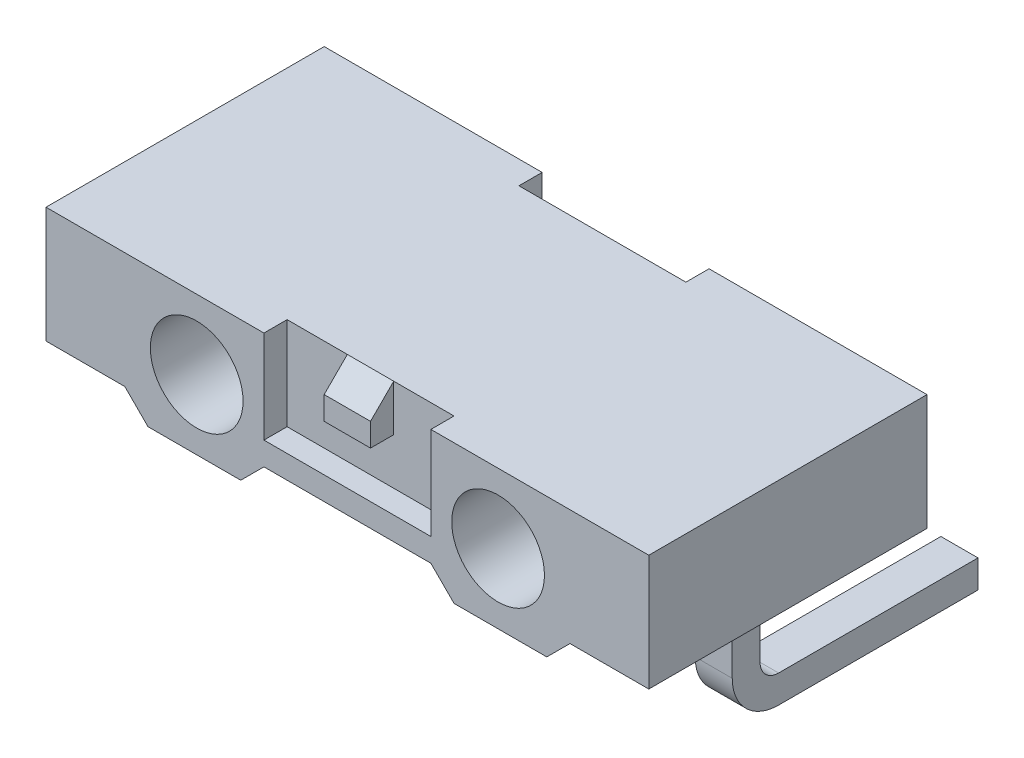
from build123d import *

# Parameters (mm, degrees)
SCHIZZO1_W                   = 13
SCHIZZO1_H                   = 2.5
ESTRUSIONE_ESTRUSIONE1_DEPTH = 3
ESTRUSIONE_ESTRUSIONE2_DEPTH = 6
SCHIZZO3_R                   = 1
TAGLIO_ESTRUSIONE1_DEPTH     = 7
TAGLIO_ESTRUSIONE2_DEPTH     = 0.5
SMUSSO1_SIZE                 = 0.5
ESTRUSIONE_ESTRUSIONE3_DEPTH = 0.4
RIPETIZIONE_A_L1_COUNT       = 2
RIPETIZIONE_A_L1_PITCH       = 5.2
RIPETIZIONE_A_L1_COL_COUNT   = 2
RIPETIZIONE_A_L1_COL_PITCH   = 5.2


with BuildPart() as part:
    # Schizzo1 → Estrusione-Estrusione1 (new body, symmetric)
    with BuildSketch(Plane.XY):
        Rectangle(SCHIZZO1_W, SCHIZZO1_H)
    extrude(amount=ESTRUSIONE_ESTRUSIONE1_DEPTH, both=True)

    # Schizzo2 → Estrusione-Estrusione2 (add)
    with BuildSketch(Plane.XY.offset(3)):
        Polygon((-4.8, -1.25), (-4.3, -1.75), (-2.3, -1.75), (-1.8, -1.25), (1.8, -1.25), (2.3, -1.75), (4.3, -1.75), (4.8, -1.25), (4.8, -0.938044121), (-4.8, -0.938044121), align=None)
    extrude(amount=-ESTRUSIONE_ESTRUSIONE2_DEPTH)

    # Schizzo3 → Taglio-Estrusione1 (cut, through all)
    with BuildSketch(Plane.XY.offset(3)):
        with Locations((-3.25, -0.25)):
            Circle(SCHIZZO3_R)
        with Locations((3.25, -0.25)):
            Circle(SCHIZZO3_R)
    extrude(amount=-TAGLIO_ESTRUSIONE1_DEPTH, mode=Mode.SUBTRACT)

    # Schizzo4 → Taglio-Estrusione2 (cut)
    with BuildSketch(Plane.XY.offset(3)):
        Polygon((-1.8, 1.25), (-0.501117074, 1.25), (-0.501117074, 0.25), (0.498882926, 0.25), (0.498882926, 1.25), (1.8, 1.25), (1.8, -0.75), (-1.8, -0.75), align=None)
    taglio_estrusione2 = extrude(amount=-TAGLIO_ESTRUSIONE2_DEPTH, mode=Mode.SUBTRACT)

    # Specchia2: Taglio-Estrusione2 across plane
    add(taglio_estrusione2.mirror(Plane.XY), mode=Mode.SUBTRACT)

    # Smusso1
    smusso1_edges = [part.edges().sort_by_distance(p)[0] for p in [
        (-0.001117074, 1.25, 3),
        (-0.001117074, 1.25, -3),
    ]]
    chamfer(smusso1_edges, length=SMUSSO1_SIZE)

    # Schizzo5 → Estrusione-Estrusione3 (add, symmetric)
    with BuildSketch(Plane(origin=(0, 0, 0), x_dir=(0, 0, -1), z_dir=(1, 0, 0))):
        with BuildLine():
            Line((-0.3, -1.25), (-0.3, -2.85))
            ThreePointArc((-0.3, -2.85), (-0.007106781, -3.557106781), (0.7, -3.85))
            Line((0.7, -3.85), (5, -3.85))
            Line((5, -3.85), (5, -3.25))
            Line((5, -3.25), (0.7, -3.25))
            ThreePointArc((0.7, -3.25), (0.417157288, -3.132842712), (0.3, -2.85))
            Line((0.3, -2.85), (0.3, -1.25))
            Line((0.3, -1.25), (-0.3, -1.25))
        make_face()
    estrusione_estrusione3 = extrude(amount=ESTRUSIONE_ESTRUSIONE3_DEPTH, both=True)

    # Ripetizione a L1: Estrusione-Estrusione3 ×2
    with Locations(*[(-i * RIPETIZIONE_A_L1_PITCH, 0, 0) for i in range(1, RIPETIZIONE_A_L1_COUNT)]):
        add(estrusione_estrusione3)

    # Ripetizione a L1 col: Estrusione-Estrusione3 ×2
    with Locations(*[(i * RIPETIZIONE_A_L1_COL_PITCH, 0, 0) for i in range(1, RIPETIZIONE_A_L1_COL_COUNT)]):
        add(estrusione_estrusione3)


solid = part.part
